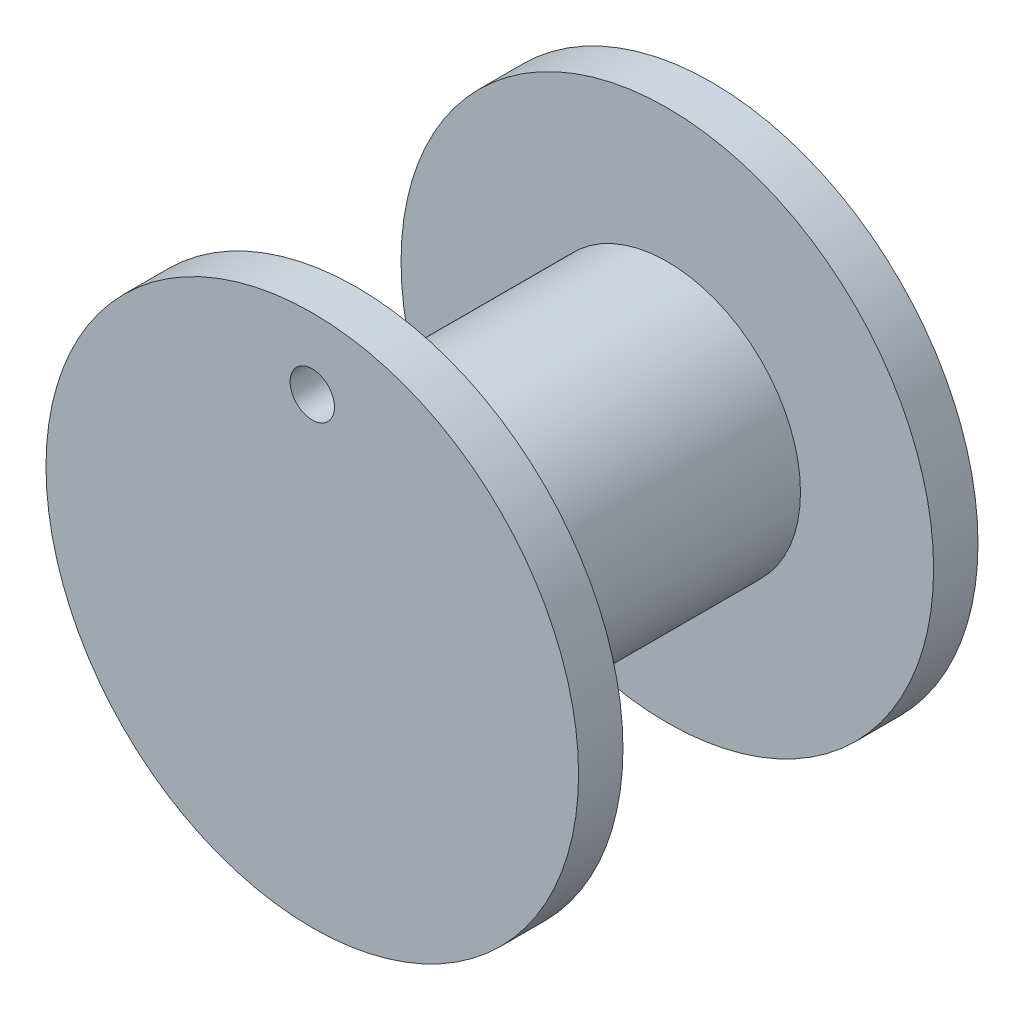
from build123d import *

# Parameters (mm, degrees)
SKETCH1_R           = 19.05
BOSS_EXTRUDE1_DEPTH = 3.175
SKETCH2_R           = 9.525
BOSS_EXTRUDE2_DEPTH = 22.225
SKETCH3_R           = 19.05
SKETCH3_R_2         = 1.5875
BOSS_EXTRUDE3_DEPTH = 3.175


with BuildPart() as part:
    # Sketch1 → Boss-Extrude1 (new body)
    with BuildSketch(Plane.XY):
        Circle(SKETCH1_R)
        Polygon((7.332348419, 0), (3.666174209, 6.35), (-3.666174209, 6.35), (-7.332348419, 0), (-3.666174209, -6.35), (3.666174209, -6.35), align=None, mode=Mode.SUBTRACT)
    extrude(amount=BOSS_EXTRUDE1_DEPTH)

    # Sketch2 → Boss-Extrude2 (add)
    with BuildSketch(Plane.XY.offset(3.175)):
        Circle(SKETCH2_R)
        Polygon((7.332348419, 0), (3.666174209, 6.35), (-3.666174209, 6.35), (-7.332348419, 0), (-3.666174209, -6.35), (3.666174209, -6.35), align=None, mode=Mode.SUBTRACT)
    extrude(amount=BOSS_EXTRUDE2_DEPTH)

    # Sketch3 → Boss-Extrude3 (add)
    with BuildSketch(Plane.XY.offset(25.4)):
        Circle(SKETCH3_R)
        with Locations((0, 13.995802971)):
            Circle(SKETCH3_R_2, mode=Mode.SUBTRACT)
    extrude(amount=BOSS_EXTRUDE3_DEPTH)


solid = part.part
